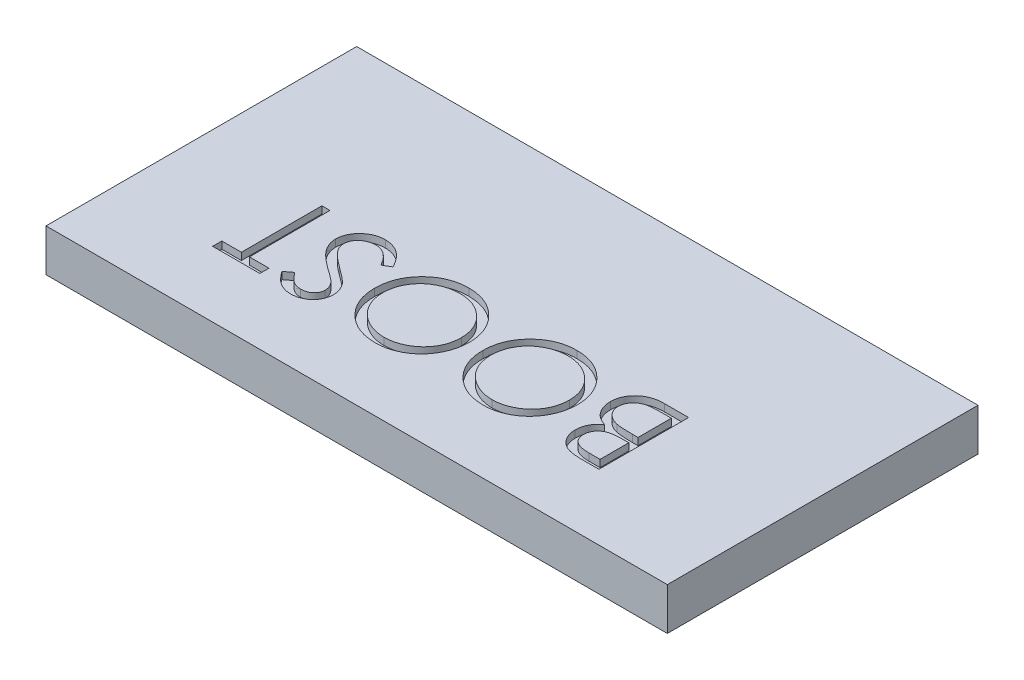
from build123d import *

# Parameters (mm, degrees)
SKETCH1_W           = 22
SKETCH1_H           = 11
BOSS_EXTRUDE1_DEPTH = 1.4986
CUT_EXTRUDE1_DEPTH  = 0.254


with BuildPart() as part:
    # Sketch1 → Boss-Extrude1 (new body)
    with BuildSketch(Plane(origin=(0, 0, 0), x_dir=(1, 0, 0), z_dir=(0, 1, 0))):
        Rectangle(SKETCH1_W, SKETCH1_H)
    extrude(amount=BOSS_EXTRUDE1_DEPTH)

    # Sketch2 → Cut-Extrude1 (cut)
    with BuildSketch(Plane(origin=(0, 1.4986, 0), x_dir=(1, 0, 0), z_dir=(0, 1, 0))):
        with BuildLine():
            Line((6.252948843, -3.175), (5.633467673, -3.175))
            add(Edge.make_bspline(
                [(5.633467673, -3.175), (5.60314279, -3.174843079), (5.544365618, -3.174538928), (5.458901624, -3.169712263), (5.378824831, -3.163295668), (5.304276745, -3.152532176), (5.234772293, -3.141371854), (5.171017091, -3.124991174), (5.11247711, -3.106898115), (5.042182574, -3.07905949), (4.962423792, -3.035825753), (4.876698025, -2.971706014), (4.802179958, -2.894831623), (4.738817512, -2.807227192), (4.687967801, -2.71085239), (4.651645679, -2.607780753), (4.628310965, -2.499746338), (4.625941303, -2.425678757), (4.624743715, -2.388246194)],
                knots=[0, 0, 0, 0, 9.0959e-05, 0.000176302, 0.000256745, 0.000331852, 0.000402223, 0.000467782, 0.000529134, 0.000585943, 0.000694367, 0.0008002, 0.000905896, 0.001014288, 0.001123535, 0.001231562, 0.00134133, 0.001453488, 0.001453488, 0.001453488, 0.001453488], degree=3))
            add(Edge.make_bspline(
                [(4.624743715, -2.388246194), (4.625721922, -2.353178326), (4.627644192, -2.284266659), (4.646423212, -2.183813262), (4.674769687, -2.087889273), (4.715675373, -1.997419107), (4.767833559, -1.913197724), (4.83129183, -1.836661725), (4.906535948, -1.769313764), (4.963029647, -1.731833665), (4.991725886, -1.712795473)],
                knots=[0, 0, 0, 0, 0.000105099, 0.000206529, 0.000305524, 0.000404587, 0.000503422, 0.000601875, 0.000701862, 0.000805081, 0.000805081, 0.000805081, 0.000805081], degree=3))
            add(Edge.make_bspline(
                [(4.991725886, -1.712795473), (4.955654939, -1.698954147), (4.88664228, -1.672472261), (4.791549052, -1.62547126), (4.709592142, -1.574742321), (4.639715351, -1.519913616), (4.581163537, -1.459194832), (4.52900323, -1.394185038), (4.484736381, -1.322620166), (4.446966883, -1.246050991), (4.417047438, -1.164882995), (4.396279184, -1.079723411), (4.38310789, -0.99153679), (4.381385503, -0.931600564), (4.380512945, -0.901236979)],
                knots=[0, 0, 0, 0, 0.000115862, 0.000221672, 0.000317675, 0.000404589, 0.000487344, 0.000570185, 0.000654188, 0.000739236, 0.000825961, 0.000913116, 0.001001804, 0.001092863, 0.001092863, 0.001092863, 0.001092863], degree=3))
            add(Edge.make_bspline(
                [(4.380512945, -0.901236979), (4.381399169, -0.870242797), (4.38314284, -0.809260874), (4.396004885, -0.719675123), (4.41778904, -0.634066271), (4.447772867, -0.551864469), (4.486858295, -0.473551149), (4.534077555, -0.398510856), (4.590750625, -0.327855697), (4.654570076, -0.26056038), (4.725774223, -0.19902172), (4.804235621, -0.146137418), (4.887943387, -0.100459073), (4.9780438, -0.063736246), (5.073897534, -0.034988989), (5.175527046, -0.015113183), (5.282874625, -0.001667075), (5.35654454, -0.000565121), (5.394325045, 0)],
                knots=[0, 0, 0, 0, 9.2965e-05, 0.000182912, 0.000270839, 0.000357564, 0.000444886, 0.000532935, 0.000623027, 0.000716149, 0.000810866, 0.000904715, 0.000999484, 0.001096453, 0.001196056, 0.001299211, 0.001406816, 0.001520092, 0.001520092, 0.001520092, 0.001520092], degree=3))
            Line((5.394325045, 0), (6.252948843, 0))
            Line((6.252948843, 0), (6.252948843, -3.175))
        make_face()
        with BuildLine():
            Line((5.968012945, -2.849358974), (5.968012945, -1.831730769))
            Line((5.968012945, -1.831730769), (5.776571639, -1.831730769))
            add(Edge.make_bspline(
                [(5.776571639, -1.831730769), (5.748587123, -1.832090538), (5.694515334, -1.832785683), (5.616002764, -1.834839708), (5.543306765, -1.840339202), (5.476176855, -1.846155836), (5.415062918, -1.855112222), (5.359760528, -1.86607244), (5.30977235, -1.877562175), (5.252152919, -1.897158708), (5.186802603, -1.925817169), (5.117625082, -1.971381864), (5.055362203, -2.024135929), (5.003998921, -2.086710494), (4.961237125, -2.154285365), (4.932447268, -2.227364451), (4.912373909, -2.303429425), (4.910586911, -2.355887766), (4.909679612, -2.382522035)],
                knots=[0, 0, 0, 0, 8.3964e-05, 0.000162235, 0.000235554, 0.000302638, 0.000364342, 0.000420722, 0.000471782, 0.000518041, 0.000603156, 0.000685012, 0.000765726, 0.000846997, 0.000926956, 0.001004553, 0.001081836, 0.001161544, 0.001161544, 0.001161544, 0.001161544], degree=3))
            add(Edge.make_bspline(
                [(4.909679612, -2.382522035), (4.910122116, -2.400154503), (4.910990137, -2.434742514), (4.919173307, -2.485135259), (4.930465985, -2.533089237), (4.949090423, -2.577311694), (4.971155568, -2.619355462), (4.999437814, -2.657892457), (5.032049846, -2.693966652), (5.070071388, -2.726611111), (5.113347015, -2.75613614), (5.163247598, -2.780714317), (5.21841646, -2.802556643), (5.280004046, -2.819113638), (5.346783586, -2.833487745), (5.4197739, -2.842551978), (5.498535097, -2.848374984), (5.553105727, -2.849023662), (5.581314227, -2.849358974)],
                knots=[0, 0, 0, 0, 5.2851e-05, 0.000103672, 0.000152881, 0.000200242, 0.000247195, 0.000295032, 0.000343206, 0.000392807, 0.000445022, 0.000499919, 0.000559328, 0.000622755, 0.000690987, 0.000764118, 0.000843191, 0.000927803, 0.000927803, 0.000927803, 0.000927803], degree=3))
            Line((5.581314227, -2.849358974), (5.968012945, -2.849358974))
        make_face(mode=Mode.SUBTRACT)
        with BuildLine():
            Line((5.968012945, -1.506089744), (5.968012945, -0.325641026))
            Line((5.968012945, -0.325641026), (5.562233699, -0.325641026))
            add(Edge.make_bspline(
                [(5.562233699, -0.325641026), (5.533190862, -0.326022613), (5.477214624, -0.326758072), (5.396333068, -0.328503216), (5.321766463, -0.334977694), (5.252893965, -0.341185023), (5.19003424, -0.351325985), (5.13257587, -0.361145936), (5.081831231, -0.375596478), (5.022457072, -0.39548068), (4.956047673, -0.42725827), (4.883525475, -0.473989938), (4.819648504, -0.530912554), (4.765453371, -0.596455715), (4.720392494, -0.666985641), (4.689219265, -0.742641147), (4.669020788, -0.820895217), (4.666641888, -0.87440248), (4.665448843, -0.901236979)],
                knots=[0, 0, 0, 0, 8.7144e-05, 0.000167958, 0.000242592, 0.000311637, 0.000375322, 0.000433575, 0.000486346, 0.000533411, 0.000621324, 0.000706353, 0.000791497, 0.000876839, 0.000960842, 0.001041518, 0.001121424, 0.001201814, 0.001201814, 0.001201814, 0.001201814], degree=3))
            add(Edge.make_bspline(
                [(4.665448843, -0.901236979), (4.66569238, -0.918015597), (4.666175526, -0.951302193), (4.6737701, -1.000174859), (4.684309427, -1.047751011), (4.699841434, -1.093384407), (4.718630939, -1.137860847), (4.743419084, -1.179733149), (4.771379928, -1.22078375), (4.814687046, -1.273292014), (4.878536597, -1.333060119), (4.969300987, -1.390845611), (5.071926229, -1.438202623), (5.146534527, -1.458222798), (5.185075245, -1.468564704)],
                knots=[0, 0, 0, 0, 5.0282e-05, 9.9752e-05, 0.000148043, 0.000196314, 0.000244168, 0.000292605, 0.000342002, 0.000393062, 0.000496563, 0.000602763, 0.000714617, 0.000834141, 0.000834141, 0.000834141, 0.000834141], degree=3))
            add(Edge.make_bspline(
                [(5.185075245, -1.468564704), (5.200523053, -1.471699169), (5.234017088, -1.478495336), (5.288634242, -1.485664702), (5.351196577, -1.492095856), (5.42143669, -1.496728084), (5.499633935, -1.501700699), (5.585763191, -1.503565733), (5.679885347, -1.505842106), (5.745192794, -1.506005086), (5.77911571, -1.506089744)],
                knots=[0, 0, 0, 0, 4.7275e-05, 0.000102503, 0.000165156, 0.000235937, 0.000313659, 0.000400195, 0.000494345, 0.00059611, 0.00059611, 0.00059611, 0.00059611], degree=3))
            Line((5.77911571, -1.506089744), (5.968012945, -1.506089744))
        make_face(mode=Mode.SUBTRACT)
        with BuildLine():
            add(Edge.make_bspline(
                [(2.243493715, -3.256410256), (2.184697106, -3.254946254), (2.069215716, -3.252070833), (1.899651025, -3.229333684), (1.737286004, -3.19190969), (1.582023677, -3.139062605), (1.434467895, -3.070540104), (1.29415215, -2.987352249), (1.161558747, -2.888681469), (1.037030628, -2.776870036), (0.92384661, -2.65396591), (0.825358172, -2.522019673), (0.741535327, -2.383687034), (0.673049065, -2.238067121), (0.619234929, -2.085810083), (0.582121462, -1.926008893), (0.5584088, -1.759724725), (0.555636997, -1.646307335), (0.554230894, -1.588772035)],
                knots=[0, 0, 0, 0, 0.000176342, 0.00034635, 0.0005122, 0.000675519, 0.000837435, 0.000999415, 0.00116402, 0.00133246, 0.001500814, 0.001664397, 0.001825613, 0.001985224, 0.002146347, 0.002309101, 0.002476673, 0.002649203, 0.002649203, 0.002649203, 0.002649203], degree=3))
            add(Edge.make_bspline(
                [(0.554230894, -1.588772035), (0.555637468, -1.531660884), (0.558409987, -1.419088189), (0.582140729, -1.253854527), (0.619400436, -1.095035243), (0.672383334, -0.94299973), (0.740920043, -0.79767334), (0.824874784, -0.659243914), (0.923141948, -0.526912937), (1.035861907, -0.403410522), (1.158953024, -0.290216063), (1.290084062, -0.190150459), (1.429096786, -0.106790074), (1.573821547, -0.037280002), (1.725698679, 0.015364591), (1.88365703, 0.053727662), (2.048592238, 0.077201348), (2.160946241, 0.079991892), (2.21805301, 0.081410256)],
                knots=[0, 0, 0, 0, 0.000171259, 0.000337571, 0.000499706, 0.000660019, 0.00081963, 0.000980845, 0.001144939, 0.001313334, 0.001481687, 0.001646036, 0.001807251, 0.001967135, 0.002126847, 0.002288512, 0.002454194, 0.002625453, 0.002625453, 0.002625453, 0.002625453], degree=3))
            add(Edge.make_bspline(
                [(2.21805301, 0.081410256), (2.27558804, 0.08000493), (2.3890049, 0.077234657), (2.555497598, 0.053481678), (2.71541261, 0.016351985), (2.86825756, -0.036760714), (3.014082605, -0.10514423), (3.152873643, -0.189177416), (3.284797452, -0.288198984), (3.408511555, -0.400830424), (3.521569521, -0.523685506), (3.62101053, -0.654644367), (3.704559247, -0.792461512), (3.772971631, -0.936568833), (3.827083221, -1.086593838), (3.864011726, -1.24348024), (3.887901269, -1.406348919), (3.890654436, -1.517240595), (3.892051407, -1.573507612)],
                knots=[0, 0, 0, 0, 0.00017253, 0.000340102, 0.000503474, 0.000664388, 0.000824575, 0.00098579, 0.001150264, 0.001318659, 0.001487012, 0.00165047, 0.001811141, 0.001969603, 0.002128328, 0.002288607, 0.0024524, 0.002621117, 0.002621117, 0.002621117, 0.002621117], degree=3))
            add(Edge.make_bspline(
                [(3.892051407, -1.573507612), (3.891566861, -1.611274563), (3.890603882, -1.686332018), (3.878993446, -1.797787037), (3.862179855, -1.907461652), (3.837957299, -2.014987191), (3.806712257, -2.120381211), (3.768208042, -2.223428176), (3.724082198, -2.32497689), (3.671544285, -2.423094702), (3.61422385, -2.517935613), (3.551721675, -2.608313719), (3.483601965, -2.69261462), (3.410837795, -2.772192898), (3.332421945, -2.845690332), (3.249534572, -2.914709337), (3.16174197, -2.978535451), (3.068905295, -3.035828152), (2.973391453, -3.088452194), (2.874507484, -3.132388939), (2.774339743, -3.171223128), (2.672005912, -3.202084794), (2.567742706, -3.22664469), (2.461419785, -3.24333252), (2.353146661, -3.254968754), (2.280201957, -3.255927688), (2.243493715, -3.256410256)],
                knots=[0, 0, 0, 0, 0.000113256, 0.000225083, 0.000335817, 0.000445988, 0.000555461, 0.000665335, 0.000775829, 0.000887357, 0.000998943, 0.001108155, 0.001216722, 0.001323853, 0.001431385, 0.001538878, 0.00164727, 0.001756689, 0.001865975, 0.001974145, 0.002081043, 0.002188079, 0.00229453, 0.002402124, 0.002510786, 0.002620863, 0.002620863, 0.002620863, 0.002620863], degree=3))
        make_face()
        with BuildLine():
            add(Edge.make_bspline(
                [(2.229501327, -2.930769231), (2.259632199, -2.930403394), (2.31960589, -2.929675219), (2.408757286, -2.920023709), (2.496768122, -2.906379841), (2.58344504, -2.88651344), (2.668865553, -2.861058301), (2.753124478, -2.829624848), (2.836297056, -2.79292842), (2.917622718, -2.750332115), (2.99580266, -2.702586079), (3.071306637, -2.652245904), (3.141251059, -2.596458377), (3.206986926, -2.537292302), (3.268354755, -2.473933045), (3.325362744, -2.406847347), (3.377954729, -2.335731494), (3.425500312, -2.260881794), (3.467812038, -2.182715173), (3.505695536, -2.102726102), (3.537099501, -2.019974472), (3.561976122, -1.934976697), (3.583090673, -1.848107339), (3.596335283, -1.758893104), (3.606079264, -1.667641544), (3.606767435, -1.605971939), (3.60711551, -1.574779647)],
                knots=[0, 0, 0, 0, 9.035e-05, 0.000179837, 0.000268716, 0.000357433, 0.000446375, 0.000535927, 0.000627047, 0.000718935, 0.000811105, 0.000901777, 0.000990976, 0.001079239, 0.001166947, 0.001255387, 0.00134316, 0.001432087, 0.00152117, 0.001609659, 0.001697425, 0.001786367, 0.001875228, 0.001965363, 0.002056748, 0.002150277, 0.002150277, 0.002150277, 0.002150277], degree=3))
            add(Edge.make_bspline(
                [(3.60711551, -1.574779647), (3.605956382, -1.528913533), (3.603676018, -1.438680696), (3.583795117, -1.306433287), (3.552928055, -1.17921419), (3.508176645, -1.05778168), (3.45108739, -0.941594257), (3.38145009, -0.83110408), (3.298627013, -0.726343743), (3.204602605, -0.628093081), (3.101789394, -0.53845151), (2.992669221, -0.459656098), (2.878105405, -0.393339682), (2.758758261, -0.337900648), (2.633608824, -0.296135187), (2.503459505, -0.266356432), (2.368307426, -0.247055975), (2.276209117, -0.245181442), (2.229501327, -0.244230769)],
                knots=[0, 0, 0, 0, 0.000137527, 0.000270558, 0.000400289, 0.000529669, 0.000657953, 0.000788002, 0.000920711, 0.001057915, 0.001195408, 0.00132938, 0.001461048, 0.001591958, 0.001723495, 0.001856022, 0.001992114, 0.002132155, 0.002132155, 0.002132155, 0.002132155], degree=3))
            add(Edge.make_bspline(
                [(2.229501327, -0.244230769), (2.19810544, -0.24466177), (2.135837968, -0.245516575), (2.043224567, -0.25413835), (1.952271017, -0.267936623), (1.863145661, -0.287901784), (1.775730641, -0.312557284), (1.690293748, -0.343144645), (1.606848257, -0.379793866), (1.525040754, -0.420703744), (1.446643182, -0.466842414), (1.372545835, -0.517537504), (1.302261434, -0.571431615), (1.236645552, -0.630169212), (1.175533923, -0.692994003), (1.119544796, -0.760363532), (1.066977332, -0.830946638), (1.019765226, -0.905777313), (0.976873066, -0.983325428), (0.940102449, -1.063547358), (0.908680438, -1.145935004), (0.883355636, -1.230569672), (0.863499603, -1.317255424), (0.849820719, -1.406117826), (0.840251574, -1.496976542), (0.839530353, -1.558429913), (0.839166792, -1.589408053)],
                knots=[0, 0, 0, 0, 9.4165e-05, 0.000186757, 0.000278778, 0.000369977, 0.000460573, 0.000551103, 0.000641966, 0.00073384, 0.000825358, 0.00091462, 0.001003036, 0.001090873, 0.001178581, 0.001265716, 0.001353488, 0.001442415, 0.00153094, 0.001619161, 0.001706927, 0.00179526, 0.001883977, 0.001973484, 0.00206487, 0.002157763, 0.002157763, 0.002157763, 0.002157763], degree=3))
            add(Edge.make_bspline(
                [(0.839166792, -1.589408053), (0.839530658, -1.62017426), (0.840252455, -1.6812047), (0.849815986, -1.771429871), (0.86351465, -1.859652427), (0.883256536, -1.94552602), (0.908702032, -2.02907254), (0.940077685, -2.110213513), (0.977075765, -2.189251252), (1.01953756, -2.265990293), (1.067267447, -2.339627643), (1.119423613, -2.410023128), (1.17690252, -2.475860664), (1.238076966, -2.538743329), (1.304417702, -2.597413391), (1.375936362, -2.651643962), (1.450852015, -2.703879246), (1.530859625, -2.750105839), (1.613131767, -2.79301814), (1.69763871, -2.829598456), (1.783323699, -2.861197924), (1.870301177, -2.88640381), (1.958420897, -2.906399139), (2.047707344, -2.920018764), (2.138127363, -2.929676256), (2.198946685, -2.93040375), (2.229501327, -2.930769231)],
                knots=[0, 0, 0, 0, 9.2258e-05, 0.00018301, 0.000271889, 0.000359986, 0.000447102, 0.00053368, 0.000620747, 0.000708715, 0.000796571, 0.000883833, 0.000971308, 0.00105856, 0.001146873, 0.001236684, 0.001327715, 0.001420652, 0.001513669, 0.001605953, 0.001696699, 0.001787471, 0.001877429, 0.001967564, 0.002058317, 0.002149939, 0.002149939, 0.002149939, 0.002149939], degree=3))
        make_face(mode=Mode.SUBTRACT)
        with BuildLine():
            add(Edge.make_bspline(
                [(-1.582788337, -3.256410256), (-1.641584945, -3.254946254), (-1.757066335, -3.252070833), (-1.926631026, -3.229333684), (-2.088996048, -3.19190969), (-2.244258375, -3.139062605), (-2.391814156, -3.070540104), (-2.532129901, -2.987352249), (-2.664723304, -2.888681469), (-2.789251423, -2.776870036), (-2.902435441, -2.65396591), (-3.000923879, -2.522019673), (-3.084746725, -2.383687034), (-3.153232986, -2.238067121), (-3.207047123, -2.085810083), (-3.244160589, -1.926008893), (-3.267873252, -1.759724725), (-3.270645054, -1.646307335), (-3.272051157, -1.588772035)],
                knots=[0, 0, 0, 0, 0.000176342, 0.00034635, 0.0005122, 0.000675519, 0.000837435, 0.000999415, 0.00116402, 0.00133246, 0.001500814, 0.001664397, 0.001825613, 0.001985224, 0.002146347, 0.002309101, 0.002476673, 0.002649203, 0.002649203, 0.002649203, 0.002649203], degree=3))
            add(Edge.make_bspline(
                [(-3.272051157, -1.588772035), (-3.270644583, -1.531660884), (-3.267872064, -1.419088189), (-3.244141322, -1.253854527), (-3.206881615, -1.095035243), (-3.153898717, -0.94299973), (-3.085362009, -0.79767334), (-3.001407267, -0.659243914), (-2.903140104, -0.526912937), (-2.790420144, -0.403410522), (-2.667329027, -0.290216063), (-2.536197989, -0.190150459), (-2.397185265, -0.106790074), (-2.252460504, -0.037280002), (-2.100583373, 0.015364591), (-1.942625021, 0.053727662), (-1.777689813, 0.077201348), (-1.665335811, 0.079991892), (-1.608229042, 0.081410256)],
                knots=[0, 0, 0, 0, 0.000171259, 0.000337571, 0.000499706, 0.000660019, 0.00081963, 0.000980845, 0.001144939, 0.001313334, 0.001481687, 0.001646036, 0.001807251, 0.001967135, 0.002126847, 0.002288512, 0.002454194, 0.002625453, 0.002625453, 0.002625453, 0.002625453], degree=3))
            add(Edge.make_bspline(
                [(-1.608229042, 0.081410256), (-1.550694011, 0.08000493), (-1.437277151, 0.077234657), (-1.270784453, 0.053481678), (-1.110869442, 0.016351985), (-0.958024492, -0.036760714), (-0.812199446, -0.10514423), (-0.673408408, -0.189177416), (-0.541484599, -0.288198984), (-0.417770497, -0.400830424), (-0.304712531, -0.523685506), (-0.205271521, -0.654644367), (-0.121722804, -0.792461512), (-0.053310421, -0.936568833), (0.00080117, -1.086593838), (0.037729675, -1.24348024), (0.061619218, -1.406348919), (0.064372384, -1.517240595), (0.065769356, -1.573507612)],
                knots=[0, 0, 0, 0, 0.00017253, 0.000340102, 0.000503474, 0.000664388, 0.000824575, 0.00098579, 0.001150264, 0.001318659, 0.001487012, 0.00165047, 0.001811141, 0.001969603, 0.002128328, 0.002288607, 0.0024524, 0.002621117, 0.002621117, 0.002621117, 0.002621117], degree=3))
            add(Edge.make_bspline(
                [(0.065769356, -1.573507612), (0.06528481, -1.611274563), (0.06432183, -1.686332018), (0.052711394, -1.797787037), (0.035897804, -1.907461652), (0.011675248, -2.014987191), (-0.019569795, -2.120381211), (-0.058074009, -2.223428176), (-0.102199853, -2.32497689), (-0.154737766, -2.423094702), (-0.212058201, -2.517935613), (-0.274560377, -2.608313719), (-0.342680086, -2.69261462), (-0.415444257, -2.772192898), (-0.493860106, -2.845690332), (-0.57674748, -2.914709337), (-0.664540081, -2.978535451), (-0.757376756, -3.035828152), (-0.852890599, -3.088452194), (-0.951774567, -3.132388939), (-1.051942308, -3.171223128), (-1.154276139, -3.202084794), (-1.258539345, -3.22664469), (-1.364862266, -3.24333252), (-1.473135391, -3.254968754), (-1.546080094, -3.255927688), (-1.582788337, -3.256410256)],
                knots=[0, 0, 0, 0, 0.000113256, 0.000225083, 0.000335817, 0.000445988, 0.000555461, 0.000665335, 0.000775829, 0.000887357, 0.000998943, 0.001108155, 0.001216722, 0.001323853, 0.001431385, 0.001538878, 0.00164727, 0.001756689, 0.001865975, 0.001974145, 0.002081043, 0.002188079, 0.00229453, 0.002402124, 0.002510786, 0.002620863, 0.002620863, 0.002620863, 0.002620863], degree=3))
        make_face()
        with BuildLine():
            add(Edge.make_bspline(
                [(-1.596780724, -2.930769231), (-1.566649852, -2.930403394), (-1.506676162, -2.929675219), (-1.417524765, -2.920023709), (-1.329513929, -2.906379841), (-1.242837011, -2.88651344), (-1.157416498, -2.861058301), (-1.073157574, -2.829624848), (-0.989984995, -2.79292842), (-0.908659334, -2.750332115), (-0.830479391, -2.702586079), (-0.754975414, -2.652245904), (-0.685030992, -2.596458377), (-0.619295125, -2.537292302), (-0.557927297, -2.473933045), (-0.500919308, -2.406847347), (-0.448327323, -2.335731494), (-0.400781739, -2.260881794), (-0.358470013, -2.182715173), (-0.320586516, -2.102726102), (-0.289182551, -2.019974472), (-0.264305929, -1.934976697), (-0.243191378, -1.848107339), (-0.229946769, -1.758893104), (-0.220202787, -1.667641544), (-0.219514616, -1.605971939), (-0.219166542, -1.574779647)],
                knots=[0, 0, 0, 0, 9.035e-05, 0.000179837, 0.000268716, 0.000357433, 0.000446375, 0.000535927, 0.000627047, 0.000718935, 0.000811105, 0.000901777, 0.000990976, 0.001079239, 0.001166947, 0.001255387, 0.00134316, 0.001432087, 0.00152117, 0.001609659, 0.001697425, 0.001786367, 0.001875228, 0.001965363, 0.002056748, 0.002150277, 0.002150277, 0.002150277, 0.002150277], degree=3))
            add(Edge.make_bspline(
                [(-0.219166542, -1.574779647), (-0.22032567, -1.528913533), (-0.222606033, -1.438680696), (-0.242486934, -1.306433287), (-0.273353996, -1.17921419), (-0.318105407, -1.05778168), (-0.375194661, -0.941594257), (-0.444831961, -0.83110408), (-0.527655039, -0.726343743), (-0.621679446, -0.628093081), (-0.724492657, -0.53845151), (-0.83361283, -0.459656098), (-0.948176646, -0.393339682), (-1.067523791, -0.337900648), (-1.192673227, -0.296135187), (-1.322822547, -0.266356432), (-1.457974625, -0.247055975), (-1.550072934, -0.245181442), (-1.596780724, -0.244230769)],
                knots=[0, 0, 0, 0, 0.000137527, 0.000270558, 0.000400289, 0.000529669, 0.000657953, 0.000788002, 0.000920711, 0.001057915, 0.001195408, 0.00132938, 0.001461048, 0.001591958, 0.001723495, 0.001856022, 0.001992114, 0.002132155, 0.002132155, 0.002132155, 0.002132155], degree=3))
            add(Edge.make_bspline(
                [(-1.596780724, -0.244230769), (-1.628176611, -0.24466177), (-1.690444084, -0.245516575), (-1.783057484, -0.25413835), (-1.874011034, -0.267936623), (-1.96313639, -0.287901784), (-2.050551411, -0.312557284), (-2.135988304, -0.343144645), (-2.219433794, -0.379793866), (-2.301241298, -0.420703744), (-2.379638869, -0.466842414), (-2.453736217, -0.517537504), (-2.524020617, -0.571431615), (-2.589636499, -0.630169212), (-2.650748129, -0.692994003), (-2.706737255, -0.760363532), (-2.759304719, -0.830946638), (-2.806516825, -0.905777313), (-2.849408986, -0.983325428), (-2.886179602, -1.063547358), (-2.917601613, -1.145935004), (-2.942926415, -1.230569672), (-2.962782448, -1.317255424), (-2.976461332, -1.406117826), (-2.986030478, -1.496976542), (-2.986751698, -1.558429913), (-2.98711526, -1.589408053)],
                knots=[0, 0, 0, 0, 9.4165e-05, 0.000186757, 0.000278778, 0.000369977, 0.000460573, 0.000551103, 0.000641966, 0.00073384, 0.000825358, 0.00091462, 0.001003036, 0.001090873, 0.001178581, 0.001265716, 0.001353488, 0.001442415, 0.00153094, 0.001619161, 0.001706927, 0.00179526, 0.001883977, 0.001973484, 0.00206487, 0.002157763, 0.002157763, 0.002157763, 0.002157763], degree=3))
            add(Edge.make_bspline(
                [(-2.98711526, -1.589408053), (-2.986751393, -1.62017426), (-2.986029596, -1.6812047), (-2.976466066, -1.771429871), (-2.962767401, -1.859652427), (-2.943025515, -1.94552602), (-2.91758002, -2.02907254), (-2.886204367, -2.110213513), (-2.849206286, -2.189251252), (-2.806744491, -2.265990293), (-2.759014605, -2.339627643), (-2.706858438, -2.410023128), (-2.649379531, -2.475860664), (-2.588205085, -2.538743329), (-2.521864349, -2.597413391), (-2.45034569, -2.651643962), (-2.375430037, -2.703879246), (-2.295422427, -2.750105839), (-2.213150285, -2.79301814), (-2.128643342, -2.829598456), (-2.042958353, -2.861197924), (-1.955980874, -2.88640381), (-1.867861154, -2.906399139), (-1.778574708, -2.920018764), (-1.688154688, -2.929676256), (-1.627335366, -2.93040375), (-1.596780724, -2.930769231)],
                knots=[0, 0, 0, 0, 9.2258e-05, 0.00018301, 0.000271889, 0.000359986, 0.000447102, 0.00053368, 0.000620747, 0.000708715, 0.000796571, 0.000883833, 0.000971308, 0.00105856, 0.001146873, 0.001236684, 0.001327715, 0.001420652, 0.001513669, 0.001605953, 0.001696699, 0.001787471, 0.001877429, 0.001967564, 0.002058317, 0.002149939, 0.002149939, 0.002149939, 0.002149939], degree=3))
        make_face(mode=Mode.SUBTRACT)
        with BuildLine():
            Line((-3.597692183, -0.612484976), (-3.866091622, -0.773397436))
            add(Edge.make_bspline(
                [(-3.866091622, -0.773397436), (-3.891054594, -0.731610458), (-3.938882686, -0.651548221), (-4.018667133, -0.543364142), (-4.101337703, -0.451414185), (-4.187506598, -0.376233263), (-4.276647851, -0.317043201), (-4.369343385, -0.275131177), (-4.465280828, -0.24899097), (-4.530571366, -0.245815892), (-4.563166942, -0.244230769)],
                knots=[0, 0, 0, 0, 0.00014596, 0.000279654, 0.00040257, 0.000516191, 0.000621858, 0.000722343, 0.000820302, 0.000917964, 0.000917964, 0.000917964, 0.000917964], degree=3))
            add(Edge.make_bspline(
                [(-4.563166942, -0.244230769), (-4.590998676, -0.245024523), (-4.646175153, -0.246598143), (-4.72756297, -0.261107727), (-4.806211517, -0.284845299), (-4.881338025, -0.317024422), (-4.950955611, -0.356578588), (-5.012972981, -0.403223773), (-5.065373354, -0.457108573), (-5.10869425, -0.516290124), (-5.142606564, -0.579533065), (-5.166735983, -0.645279892), (-5.1822362, -0.713111649), (-5.184201405, -0.759110766), (-5.185192183, -0.782301683)],
                knots=[0, 0, 0, 0, 8.3437e-05, 0.000165414, 0.000247107, 0.000329451, 0.000410075, 0.000486781, 0.000561442, 0.000634716, 0.000706137, 0.000775963, 0.000844329, 0.000913841, 0.000913841, 0.000913841, 0.000913841], degree=3))
            add(Edge.make_bspline(
                [(-5.185192183, -0.782301683), (-5.183883497, -0.80874542), (-5.181233266, -0.86229687), (-5.157876601, -0.941440927), (-5.122211952, -1.020101336), (-5.08869119, -1.068767031), (-5.071345027, -1.093950321)],
                knots=[0, 0, 0, 0, 7.9176e-05, 0.00016034, 0.000245718, 0.00033728, 0.00033728, 0.00033728, 0.00033728], degree=3))
            add(Edge.make_bspline(
                [(-5.071345027, -1.093950321), (-5.057171875, -1.112175133), (-5.027329772, -1.150548157), (-4.975271322, -1.20666466), (-4.916077584, -1.266081679), (-4.848216012, -1.327613262), (-4.772676171, -1.392518085), (-4.688601654, -1.459592409), (-4.59697416, -1.529836622), (-4.532346621, -1.576230904), (-4.498929162, -1.600220353)],
                knots=[0, 0, 0, 0, 6.9232e-05, 0.000145772, 0.000229422, 0.000320807, 0.000420492, 0.000528165, 0.000643416, 0.000766818, 0.000766818, 0.000766818, 0.000766818], degree=3))
            add(Edge.make_bspline(
                [(-4.498929162, -1.600220353), (-4.465528993, -1.624018874), (-4.401670412, -1.669519836), (-4.312296808, -1.736962888), (-4.232484284, -1.799017949), (-4.161826156, -1.854820612), (-4.10215044, -1.906804708), (-4.051275558, -1.952184181), (-4.011078477, -1.993382241), (-3.988709749, -2.020086685), (-3.978666742, -2.032076322)],
                knots=[0, 0, 0, 0, 0.00012303, 0.000235223, 0.000335855, 0.000426344, 0.000505264, 0.000573246, 0.000630819, 0.000677729, 0.000677729, 0.000677729, 0.000677729], degree=3))
            add(Edge.make_bspline(
                [(-3.978666742, -2.032076322), (-3.964633286, -2.050765333), (-3.93703461, -2.087519782), (-3.900564782, -2.144951255), (-3.869809676, -2.203629868), (-3.845057566, -2.263768287), (-3.825041472, -2.324914535), (-3.811125153, -2.387527674), (-3.802547427, -2.451182649), (-3.801661373, -2.494010556), (-3.801217824, -2.51544972)],
                knots=[0, 0, 0, 0, 7.0095e-05, 0.000137851, 0.00020385, 0.000268577, 0.000332739, 0.00039662, 0.000460757, 0.000525045, 0.000525045, 0.000525045, 0.000525045], degree=3))
            add(Edge.make_bspline(
                [(-3.801217824, -2.51544972), (-3.802396617, -2.549043893), (-3.804729009, -2.615514189), (-3.824617175, -2.712564684), (-3.855637361, -2.805509219), (-3.900516459, -2.892279183), (-3.955950541, -2.972751576), (-4.021750902, -3.045498884), (-4.099149796, -3.108017057), (-4.185314532, -3.161162502), (-4.278527017, -3.203560713), (-4.376487871, -3.234454706), (-4.478756912, -3.252560472), (-4.548255522, -3.255114386), (-4.583519507, -3.256410256)],
                knots=[0, 0, 0, 0, 0.000100692, 0.000199231, 0.000295975, 0.000393825, 0.00049121, 0.000588457, 0.000686996, 0.000788664, 0.000891411, 0.000993399, 0.001096081, 0.001201852, 0.001201852, 0.001201852, 0.001201852], degree=3))
            add(Edge.make_bspline(
                [(-4.583519507, -3.256410256), (-4.62094536, -3.255161392), (-4.695165303, -3.252684746), (-4.804371264, -3.229826556), (-4.910142162, -3.194310897), (-4.994909236, -3.152012432), (-5.061276365, -3.110221615), (-5.111835213, -3.07206033), (-5.163348646, -3.028222277), (-5.215261628, -2.977778761), (-5.26808707, -2.921740037), (-5.321581522, -2.859631337), (-5.376245636, -2.792012477), (-5.411400762, -2.743728186), (-5.429422952, -2.718975361)],
                knots=[0, 0, 0, 0, 0.000112158, 0.000222422, 0.000333244, 0.000446165, 0.000505629, 0.00056834, 0.000636016, 0.000708435, 0.000785372, 0.000866984, 0.000954294, 0.001046137, 0.001046137, 0.001046137, 0.001046137], degree=3))
            Line((-5.429422952, -2.718975361), (-5.171835813, -2.523717949))
            add(Edge.make_bspline(
                [(-5.171835813, -2.523717949), (-5.156283137, -2.543756707), (-5.126332319, -2.582346669), (-5.080842626, -2.63637093), (-5.038032476, -2.685786748), (-4.995531325, -2.728595243), (-4.956615298, -2.76800256), (-4.918173764, -2.801141703), (-4.881691776, -2.82906474), (-4.835811614, -2.858902893), (-4.777543679, -2.887771526), (-4.705082003, -2.912591669), (-4.629307515, -2.927845119), (-4.577865889, -2.929783812), (-4.551718625, -2.930769231)],
                knots=[0, 0, 0, 0, 7.6089e-05, 0.000146529, 0.000211865, 0.000272136, 0.000327455, 0.000377954, 0.000424256, 0.000465184, 0.000541982, 0.000618614, 0.000694452, 0.000772847, 0.000772847, 0.000772847, 0.000772847], degree=3))
            add(Edge.make_bspline(
                [(-4.551718625, -2.930769231), (-4.518911754, -2.929688044), (-4.455646793, -2.927603078), (-4.366038323, -2.904232925), (-4.284920296, -2.868700181), (-4.215389378, -2.817462336), (-4.157978778, -2.756376955), (-4.115934797, -2.68671338), (-4.090797439, -2.609772672), (-4.08772067, -2.556126979), (-4.086153721, -2.52880609)],
                knots=[0, 0, 0, 0, 9.8196e-05, 0.000189362, 0.000275898, 0.000362406, 0.000446565, 0.000525863, 0.000604709, 0.000686538, 0.000686538, 0.000686538, 0.000686538], degree=3))
            add(Edge.make_bspline(
                [(-4.086153721, -2.52880609), (-4.086547568, -2.511804191), (-4.087340749, -2.477563549), (-4.096797387, -2.427079329), (-4.110909436, -2.377189424), (-4.130912877, -2.327606397), (-4.158097789, -2.27691767), (-4.195019672, -2.225412158), (-4.24122252, -2.171800813), (-4.276681989, -2.136966296), (-4.295403521, -2.11857472)],
                knots=[0, 0, 0, 0, 5.0945e-05, 0.0001026, 0.000153533, 0.000206326, 0.00026267, 0.000325665, 0.00039603, 0.000474735, 0.000474735, 0.000474735, 0.000474735], degree=3))
            add(Edge.make_bspline(
                [(-4.295403521, -2.11857472), (-4.30235348, -2.11237256), (-4.318864993, -2.09763765), (-4.349051011, -2.073514653), (-4.388913406, -2.043757852), (-4.43741126, -2.006939358), (-4.495438796, -1.964229746), (-4.563002393, -1.916175112), (-4.639348926, -1.861215445), (-4.693525236, -1.822791105), (-4.722171349, -1.802473958)],
                knots=[0, 0, 0, 0, 2.7941e-05, 6.6382e-05, 0.000115865, 0.000177177, 0.00024905, 0.000332006, 0.000425904, 0.000531263, 0.000531263, 0.000531263, 0.000531263], degree=3))
            add(Edge.make_bspline(
                [(-4.722171349, -1.802473958), (-4.756629975, -1.777399279), (-4.823354328, -1.728845637), (-4.918294033, -1.655897367), (-5.004375147, -1.584551785), (-5.081906264, -1.51526914), (-5.151632005, -1.448559477), (-5.212849495, -1.383671938), (-5.265836491, -1.321032045), (-5.323659819, -1.241269918), (-5.38204424, -1.142401842), (-5.432104083, -1.021215199), (-5.463951297, -0.899680788), (-5.468087372, -0.818100612), (-5.47012808, -0.777849559)],
                knots=[0, 0, 0, 0, 0.000127846, 0.000247556, 0.00035912, 0.000463173, 0.000559432, 0.00064852, 0.000730687, 0.000805364, 0.0009439, 0.001073941, 0.00119781, 0.001318447, 0.001318447, 0.001318447, 0.001318447], degree=3))
            add(Edge.make_bspline(
                [(-5.47012808, -0.777849559), (-5.469531023, -0.749385426), (-5.468348503, -0.693009912), (-5.454790471, -0.610220872), (-5.434855422, -0.529848461), (-5.40514463, -0.452892879), (-5.368005276, -0.37849645), (-5.322788409, -0.306789617), (-5.267990716, -0.238950603), (-5.207117053, -0.173661953), (-5.139501815, -0.114614824), (-5.067951088, -0.062022474), (-4.992866469, -0.01699173), (-4.913390506, 0.018385422), (-4.830832385, 0.046684119), (-4.744804569, 0.06696788), (-4.655122204, 0.079459274), (-4.594160886, 0.080752669), (-4.563166942, 0.081410256)],
                knots=[0, 0, 0, 0, 8.5312e-05, 0.000168967, 0.000251033, 0.000333365, 0.000415851, 0.000500192, 0.000587106, 0.000677093, 0.000767678, 0.000855963, 0.000943225, 0.001029761, 0.001116448, 0.00120469, 0.001294549, 0.001387486, 0.001387486, 0.001387486, 0.001387486], degree=3))
            add(Edge.make_bspline(
                [(-4.563166942, 0.081410256), (-4.539187368, 0.080941228), (-4.491530218, 0.080009079), (-4.421228734, 0.07196351), (-4.352218204, 0.060164582), (-4.285365116, 0.042175506), (-4.219837105, 0.019835875), (-4.156217979, -0.007515565), (-4.094354269, -0.040076834), (-4.034169557, -0.077898299), (-3.975112981, -0.121497566), (-3.917422887, -0.171837516), (-3.86081048, -0.228677189), (-3.805040599, -0.291937488), (-3.751426973, -0.36266406), (-3.698621381, -0.439735266), (-3.646898783, -0.523400093), (-3.614400741, -0.582235375), (-3.597692183, -0.612484976)],
                knots=[0, 0, 0, 0, 7.1915e-05, 0.000142924, 0.000212043, 0.000281773, 0.00035036, 0.000419592, 0.000489294, 0.00055988, 0.000632642, 0.000709287, 0.000789339, 0.000873164, 0.000962083, 0.001055407, 0.001153366, 0.001257027, 0.001257027, 0.001257027, 0.001257027], degree=3))
        make_face()
        Polygon((-5.755063978, -2.849358974), (-5.755063978, -3.175), (-7.423974234, -3.175), (-7.423974234, -2.849358974), (-6.731987055, -2.849358974), (-6.731987055, 0), (-6.447051157, 0), (-6.447051157, -2.849358974), align=None)
    extrude(amount=-CUT_EXTRUDE1_DEPTH, mode=Mode.SUBTRACT)


solid = part.part
